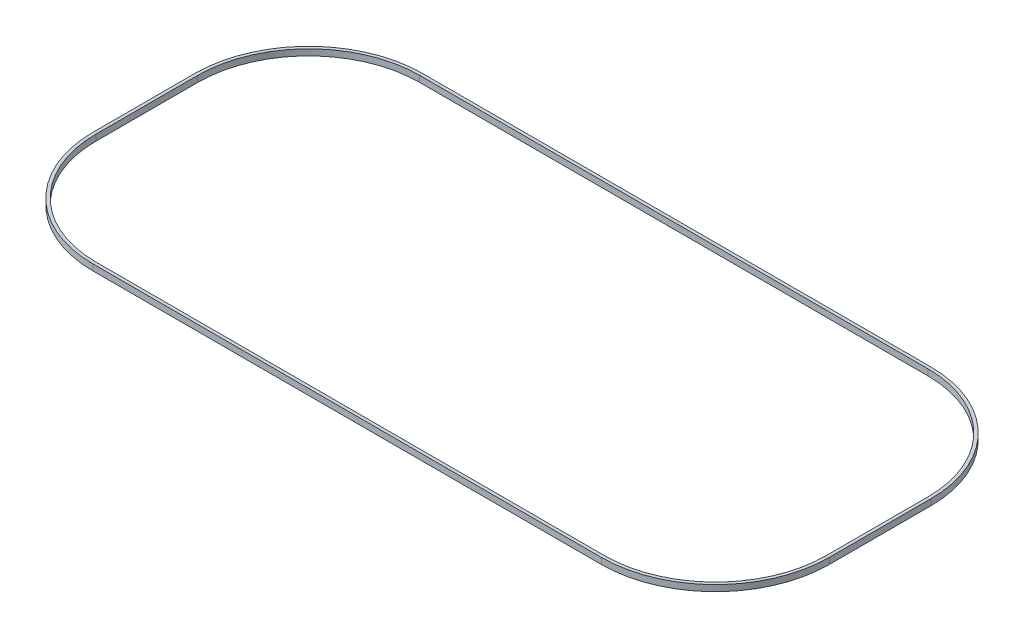
from build123d import *

# Parameters (mm, degrees)
BOSS_EXTRUDE1_DEPTH = 1.016
CUT_EXTRUDE7_DEPTH  = 2.54


with BuildPart() as part:
    # Sketch1 → Boss-Extrude1 (new body)
    with BuildSketch(Plane(origin=(0, 0, 0), x_dir=(1, 0, 0), z_dir=(0, 1, 0))):
        with BuildLine():
            Line((0, 0), (83.82, 0))
            ThreePointArc((83.82, 0), (98.912902724, 6.251685004), (105.164587728, 21.344587728))
            Line((105.164587728, 21.344587728), (105.164587728, 38.108587728))
            ThreePointArc((105.164587728, 38.108587728), (98.912902724, 53.201490452), (83.82, 59.453175456))
            Line((83.82, 59.453175456), (0, 59.453175456))
            ThreePointArc((0, 59.453175456), (-15.092902724, 53.201490452), (-21.344587728, 38.108587728))
            Line((-21.344587728, 38.108587728), (-21.344587728, 21.344587728))
            ThreePointArc((-21.344587728, 21.344587728), (-15.092902724, 6.251685004), (0, 0))
        make_face()
        with BuildLine():
            Line((0, 3.048), (83.82, 3.048))
            ThreePointArc((83.82, 3.048), (96.757641255, 8.406946473), (102.116587728, 21.344587728))
            Line((102.116587728, 21.344587728), (102.116587728, 38.108587728))
            ThreePointArc((102.116587728, 38.108587728), (96.757641255, 51.046228983), (83.82, 56.405175456))
            Line((83.82, 56.405175456), (0, 56.405175456))
            ThreePointArc((0, 56.405175456), (-12.937641255, 51.046228983), (-18.296587728, 38.108587728))
            Line((-18.296587728, 38.108587728), (-18.296587728, 21.344587728))
            ThreePointArc((-18.296587728, 21.344587728), (-12.937641255, 8.406946473), (0, 3.048))
        make_face(mode=Mode.SUBTRACT)
    extrude(amount=BOSS_EXTRUDE1_DEPTH)

    # Sketch6 → Cut-Extrude7 (cut)
    with BuildSketch(Plane(origin=(0, 1.016, 0), x_dir=(1, 0, 0), z_dir=(0, 1, 0))):
        with BuildLine():
            Line((0, 0), (83.82, 0))
            ThreePointArc((83.82, 0), (98.912902724, 6.251685004), (105.164587728, 21.344587728))
            Line((105.164587728, 21.344587728), (105.164587728, 38.108587728))
            ThreePointArc((105.164587728, 38.108587728), (98.912902724, 53.201490452), (83.82, 59.453175456))
            Line((83.82, 59.453175456), (0, 59.453175456))
            ThreePointArc((0, 59.453175456), (-15.092902724, 53.201490452), (-21.344587728, 38.108587728))
            Line((-21.344587728, 38.108587728), (-21.344587728, 21.344587728))
            ThreePointArc((-21.344587728, 21.344587728), (-15.092902724, 6.251685004), (0, 0))
        make_face()
        with BuildLine():
            Line((0, 2.54), (83.82, 2.54))
            ThreePointArc((83.82, 2.54), (97.1168515, 8.047736228), (102.624587728, 21.344587728))
            Line((102.624587728, 21.344587728), (102.624587728, 38.108587728))
            ThreePointArc((102.624587728, 38.108587728), (97.1168515, 51.405439228), (83.82, 56.913175456))
            Line((83.82, 56.913175456), (0, 56.913175456))
            ThreePointArc((0, 56.913175456), (-13.2968515, 51.405439228), (-18.804587728, 38.108587728))
            Line((-18.804587728, 38.108587728), (-18.804587728, 21.344587728))
            ThreePointArc((-18.804587728, 21.344587728), (-13.2968515, 8.047736228), (0, 2.54))
        make_face(mode=Mode.SUBTRACT)
    extrude(amount=-CUT_EXTRUDE7_DEPTH, mode=Mode.SUBTRACT)


solid = part.part
